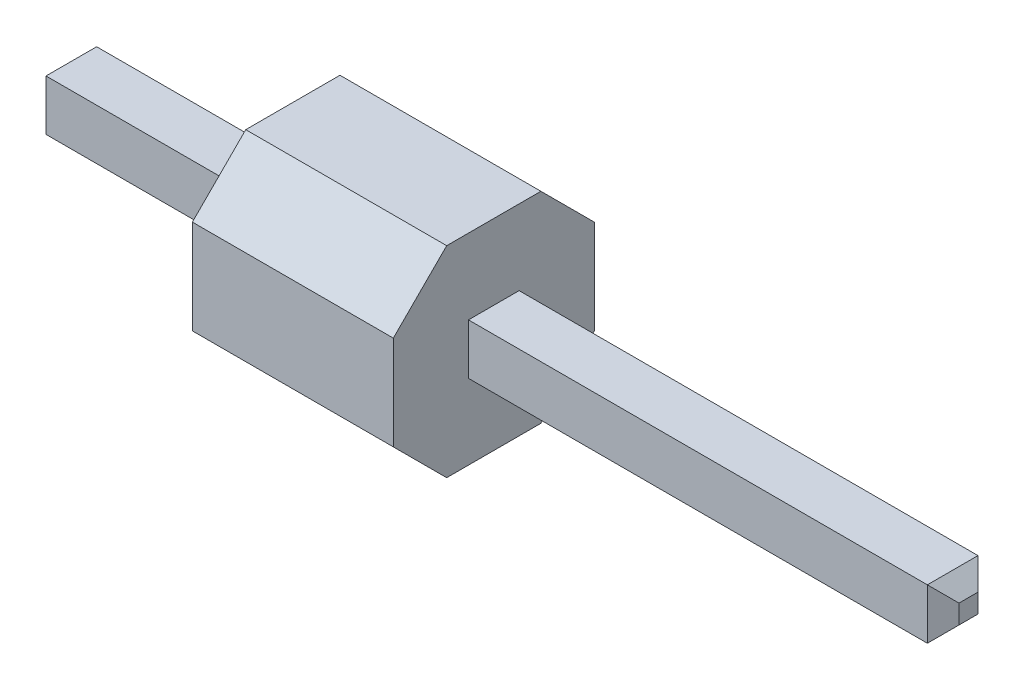
from build123d import *

# Parameters (mm, degrees)
CROQUIS1_W                   = 0.64
CROQUIS1_H                   = 0.64
SALIENTE_EXTRUIR1_DEPTH      = 2.54
CORTAR_EXTRUIR1_DEPTH        = 2.54
CORTAR_EXTRUIR1_DEPTH_BACK   = 2.54
CROQUIS3_W                   = 0.64
CROQUIS3_H                   = 0.64
SALIENTE_EXTRUIR2_DEPTH      = 8.54
SALIENTE_EXTRUIR2_DEPTH_BACK = 3
CHAFL_N1_SIZE                = 0.2


with BuildPart() as part:
    # Croquis1 → Saliente-Extruir1 (new body)
    with BuildSketch(Plane(origin=(0, 0, 0), x_dir=(0, 0, -1), z_dir=(1, 0, 0))):
        Polygon((-0.595482683, 1.27), (-1.27, 0.595482683), (-1.27, -0.595482683), (-0.595482683, -1.27), (0.595482683, -1.27), (1.27, -0.595482683), (1.27, 0.595482683), (0.595482683, 1.27), align=None)
        Rectangle(CROQUIS1_W, CROQUIS1_H, mode=Mode.SUBTRACT)
    extrude(amount=SALIENTE_EXTRUIR1_DEPTH)

    # Croquis2 → Cortar-Extruir1 (cut, two sides)
    with BuildSketch(Plane(origin=(0, 0, 0), x_dir=(1, 0, 0), z_dir=(0, 1, 0))) as cortar_extruir1_sk:
        with BuildLine():
            Line((0.516526244, 1.243275937), (0.516526244, 1.296724063))
            ThreePointArc((0.516526244, 1.296724063), (0.500491193, 1.351036929), (0.457528496, 1.387931603))
            Line((0.457528496, 1.387931603), (0, 1.593613049))
            Line((0, 1.593613049), (0, 0.946386951))
            Line((0, 0.946386951), (0.457528496, 1.152068397))
            ThreePointArc((0.457528496, 1.152068397), (0.500491193, 1.188963071), (0.516526244, 1.243275937))
        make_face()
    extrude(amount=CORTAR_EXTRUIR1_DEPTH, mode=Mode.SUBTRACT)
    extrude(cortar_extruir1_sk.sketch, amount=-CORTAR_EXTRUIR1_DEPTH_BACK, mode=Mode.SUBTRACT)


with BuildPart() as body_2:
    # Croquis3 → Saliente-Extruir2 (new body, two sides)
    with BuildSketch(Plane(origin=(0, 0, 0), x_dir=(0, 0, -1), z_dir=(1, 0, 0))) as saliente_extruir2_sk:
        Rectangle(CROQUIS3_W, CROQUIS3_H)
    extrude(amount=SALIENTE_EXTRUIR2_DEPTH)
    extrude(saliente_extruir2_sk.sketch, amount=-SALIENTE_EXTRUIR2_DEPTH_BACK)

    # Chaflán1
    chafl_n1_edges = [body_2.edges().sort_by_distance(p)[0] for p in [
        (-3, 0, -0.32),
        (8.54, 0, 0.32),
        (8.54, -0.32, 0),
        (-3, 0.32, 0),
        (8.54, 0, -0.32),
        (8.54, 0.32, 0),
        (-3, 0, 0.32),
        (-3, -0.32, 0),
    ]]
    chamfer(chafl_n1_edges, length=CHAFL_N1_SIZE)


solid = Compound([part.part, body_2.part])
